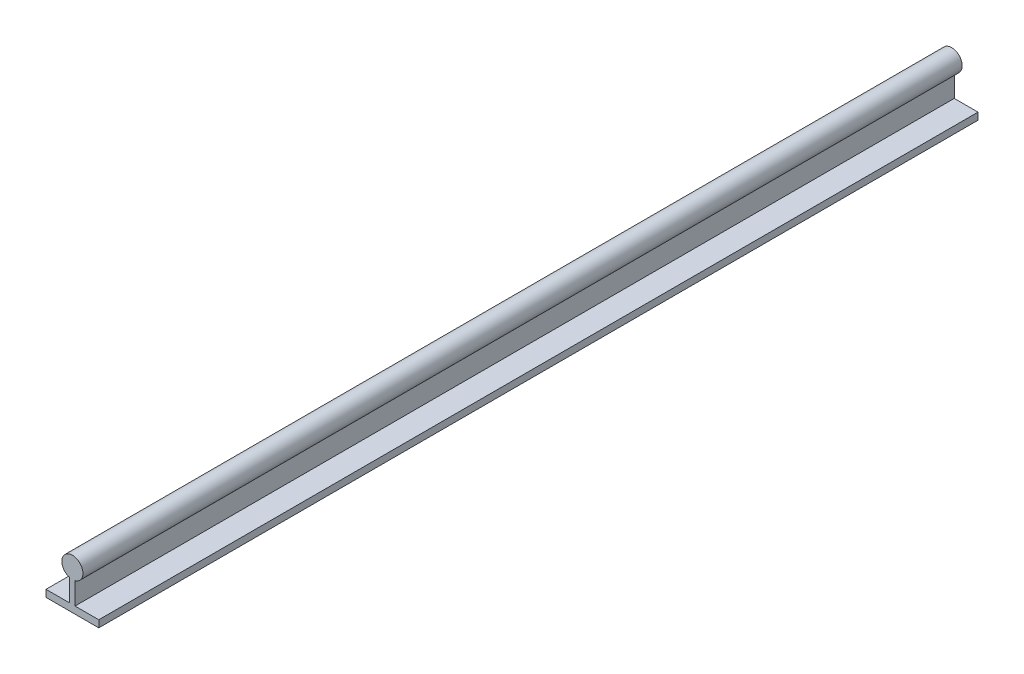
from build123d import *

# Parameters (mm, degrees)
BOSS_EXTRUDE1_DEPTH = 500


with BuildPart() as part:
    # Sketch1 → Boss-Extrude1 (new body)
    with BuildSketch(Plane.XY):
        with BuildLine():
            Line((1.5, -18.3), (15, -18.3))
            Line((15, -18.3), (15, -22.3))
            Line((15, -22.3), (-15, -22.3))
            Line((-15, -22.3), (-15, -18.3))
            Line((-15, -18.3), (-1.5, -18.3))
            Line((-1.5, -18.3), (-1.5, -5.809475019))
            ThreePointArc((-1.5, -5.809475019), (0, 6), (1.5, -5.809475019))
            Line((1.5, -5.809475019), (1.5, -18.3))
        make_face()
    extrude(amount=BOSS_EXTRUDE1_DEPTH)


solid = part.part
